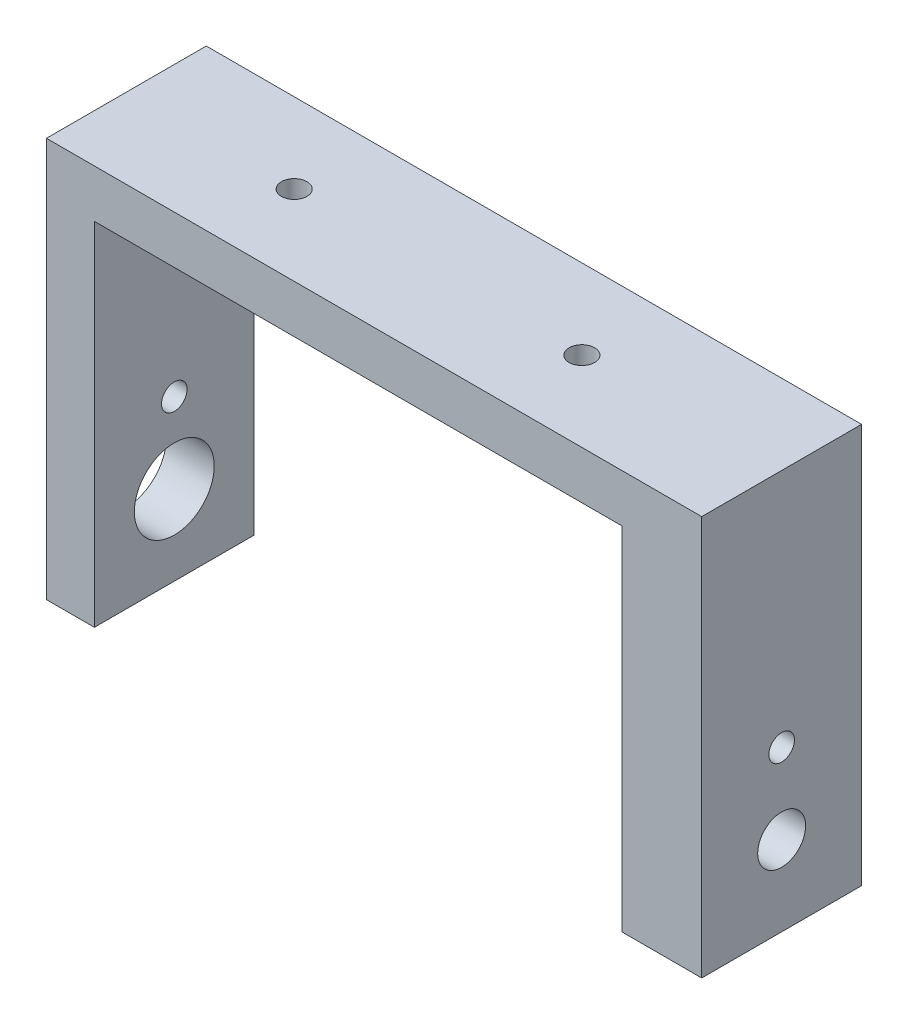
from build123d import *

# Parameters (mm, degrees)
BOSS_EXTRUDE1_DEPTH = 10
SKETCH4_R           = 1.5
SKETCH4_R_2         = 0.8
CUT_EXTRUDE1_DEPTH  = 42
SKETCH6_R           = 0.8
CUT_EXTRUDE2_DEPTH  = 26
CUT_EXTRUDE3_DEPTH  = 2
SKETCH9_R           = 2.5
CUT_EXTRUDE4_DEPTH  = 10


with BuildPart() as part:
    # Sketch2 → Boss-Extrude1 (new body)
    with BuildSketch(Plane.XY):
        Polygon((-16.5, -11), (-19.5, -11), (-19.5, 14), (21.5, 14), (21.5, -11), (16.5, -11), (16.5, 11), (-16.5, 11), align=None)
    extrude(amount=BOSS_EXTRUDE1_DEPTH)

    # Sketch4 → Cut-Extrude1 (cut, through all)
    with BuildSketch(Plane.ZY.offset(19.5)):
        with Locations((5, -6)):
            Circle(SKETCH4_R)
        with Locations((5, -1)):
            Circle(SKETCH4_R_2)
    extrude(amount=-CUT_EXTRUDE1_DEPTH, mode=Mode.SUBTRACT)

    # Sketch6 → Cut-Extrude2 (cut, through all)
    with BuildSketch(Plane(origin=(0, 14, 0), x_dir=(1, 0, 0), z_dir=(0, 1, 0))):
        with Locations((-9, -5)):
            Circle(SKETCH6_R)
        with Locations((9, -5)):
            Circle(SKETCH6_R)
    extrude(amount=-CUT_EXTRUDE2_DEPTH, mode=Mode.SUBTRACT)

    # Sketch8 → Cut-Extrude3 (cut)
    with BuildSketch(Plane.ZY.offset(-16.5)):
        Polygon((1, -1), (1, -11), (9, -11), (9, -1), (7, 12), (3, 12), align=None)
    extrude(amount=-CUT_EXTRUDE3_DEPTH, mode=Mode.SUBTRACT)

    # Sketch9 → Cut-Extrude4 (cut)
    with BuildSketch(Plane.ZY.offset(19.5)):
        with Locations((5, -6)):
            Circle(SKETCH9_R)
    extrude(amount=-CUT_EXTRUDE4_DEPTH, mode=Mode.SUBTRACT)


solid = part.part
